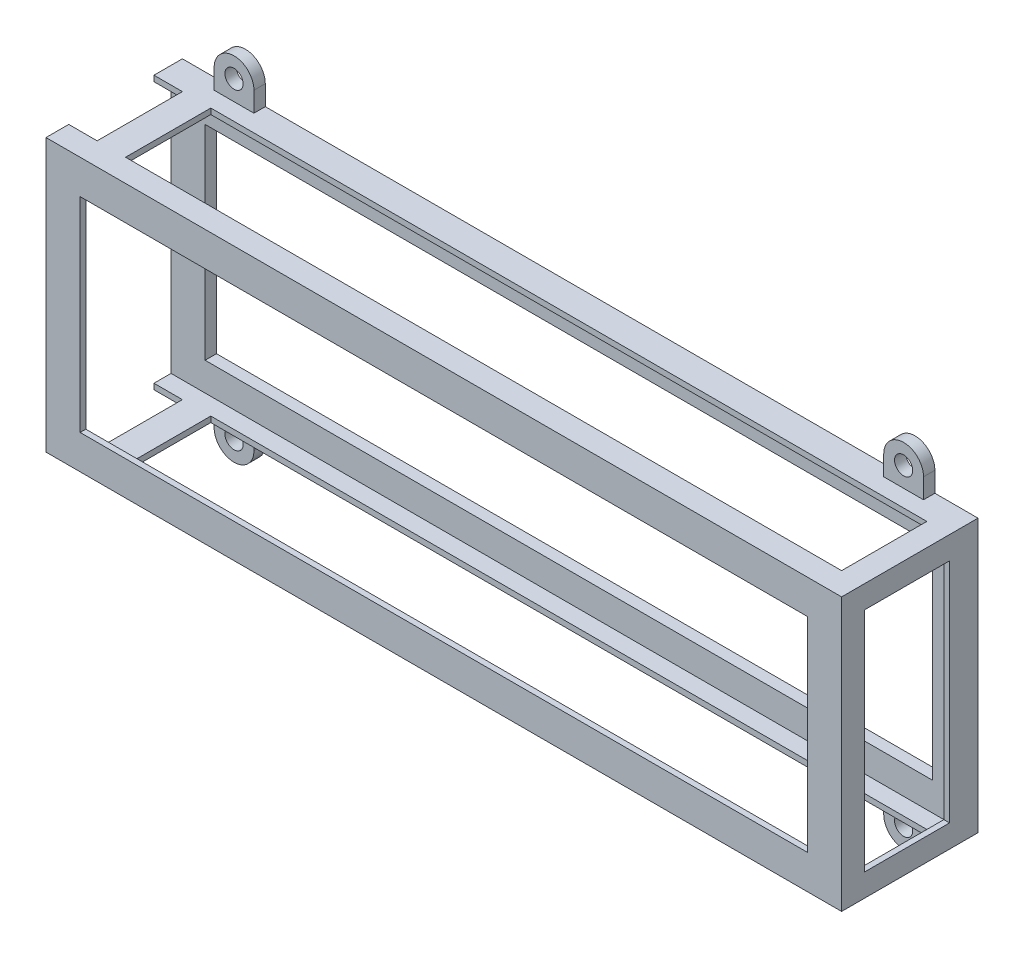
from build123d import *

# Parameters (mm, degrees)
SKETCH1_R           = 1.6
SKETCH1_R_2         = 2.1
BOSS_EXTRUDE3_DEPTH = 2
BOSS_EXTRUDE4_DEPTH = 2
SKETCH4_W           = 66
SKETCH4_H           = 16.340111315
SKETCH4_H_2         = 24.741581589
CUT_EXTRUDE3_DEPTH  = 14.5
FILLET1_R           = 4
SKETCH5_W           = 26
SKETCH5_H           = 27
SKETCH5_R           = 6
BOSS_EXTRUDE5_DEPTH = 2
SKETCH6_W           = 5
SKETCH6_H           = 27
CUT_EXTRUDE4_DEPTH  = 14.5
SKETCH7_R           = 1.6
SKETCH7_W           = 110.82382425
SKETCH7_H           = 47.94215156
BOSS_EXTRUDE6_DEPTH = 2
SKETCH8_W           = 110.82382425
SKETCH8_H           = 47.94215156
CUT_EXTRUDE5_DEPTH  = 10
BOSS_EXTRUDE7_DEPTH = 2
BOSS_EXTRUDE8_DEPTH = 21
SKETCH11_W          = 140
SKETCH11_H          = 47.94215156
BOSS_EXTRUDE9_DEPTH = 1
CUT_EXTRUDE7_DEPTH  = 13
CUT_EXTRUDE8_DEPTH  = 13
CUT_EXTRUDE9_DEPTH  = 66
CUT_EXTRUDE11_DEPTH = 66
CUT_EXTRUDE12_DEPTH = 66


with BuildPart() as part:
    # Sketch1 → Boss-Extrude3 (new body)
    with BuildSketch(Plane.XY):
        with BuildLine():
            Line((0, 3.5), (37.911912125, 3.5))
            Line((37.911912125, 3.5), (37.911912125, 13.97107578))
            Line((37.911912125, 13.97107578), (37.911912125, 40.97107578))
            Line((37.911912125, 40.97107578), (37.911912125, 51.44215156))
            Line((37.911912125, 51.44215156), (0, 51.44215156))
            ThreePointArc((0, 51.44215156), (-3.5, 54.94215156), (0, 58.44215156))
            Line((0, 58.44215156), (45.911912125, 58.44215156))
            Line((45.911912125, 58.44215156), (45.911912125, 51.44215156))
            Line((45.911912125, 51.44215156), (45.911912125, 48.97107578))
            Line((45.911912125, 48.97107578), (50.911912125, 48.97107578))
            Line((50.911912125, 48.97107578), (66.911912125, 48.97107578))
            Line((66.911912125, 48.97107578), (71.911912125, 48.97107578))
            Line((71.911912125, 48.97107578), (71.911912125, 51.44215156))
            Line((71.911912125, 51.44215156), (71.911912125, 58.44215156))
            Line((71.911912125, 58.44215156), (117.82382425, 58.44215156))
            ThreePointArc((117.82382425, 58.44215156), (121.32382425, 54.94215156), (117.82382425, 51.44215156))
            Line((117.82382425, 51.44215156), (79.911912125, 51.44215156))
            Line((79.911912125, 51.44215156), (79.911912125, 40.97107578))
            Line((79.911912125, 40.97107578), (79.911912125, 13.97107578))
            Line((79.911912125, 13.97107578), (79.911912125, 3.5))
            Line((79.911912125, 3.5), (117.82382425, 3.5))
            ThreePointArc((117.82382425, 3.5), (121.32382425, 0), (117.82382425, -3.5))
            Line((117.82382425, -3.5), (71.911912125, -3.5))
            Line((71.911912125, -3.5), (71.911912125, 3.5))
            Line((71.911912125, 3.5), (71.911912125, 5.97107578))
            Line((71.911912125, 5.97107578), (66.911912125, 5.97107578))
            Line((66.911912125, 5.97107578), (50.911912125, 5.97107578))
            Line((50.911912125, 5.97107578), (45.911912125, 5.97107578))
            Line((45.911912125, 5.97107578), (45.911912125, 3.5))
            Line((45.911912125, 3.5), (45.911912125, -3.5))
            Line((45.911912125, -3.5), (0, -3.5))
            ThreePointArc((0, -3.5), (-3.5, 0), (0, 3.5))
        make_face()
        with Locations((0, 54.94215156)):
            Circle(SKETCH1_R, mode=Mode.SUBTRACT)
        with Locations((117.82382425, 54.94215156)):
            Circle(SKETCH1_R, mode=Mode.SUBTRACT)
        with Locations((117.82382425, 0)):
            Circle(SKETCH1_R, mode=Mode.SUBTRACT)
        Circle(SKETCH1_R, mode=Mode.SUBTRACT)
        with Locations((66.911912125, 44.97107578)):
            Circle(SKETCH1_R_2, mode=Mode.SUBTRACT)
        with Locations((66.911912125, 9.97107578)):
            Circle(SKETCH1_R_2, mode=Mode.SUBTRACT)
        with Locations((50.911912125, 9.97107578)):
            Circle(SKETCH1_R_2, mode=Mode.SUBTRACT)
        with Locations((50.911912125, 44.97107578)):
            Circle(SKETCH1_R_2, mode=Mode.SUBTRACT)
        Polygon((66.911912125, 40.97107578), (50.911912125, 40.97107578), (45.911912125, 40.97107578), (45.911912125, 27.47107578), (45.911912125, 13.97107578), (50.911912125, 13.97107578), (66.911912125, 13.97107578), (71.911912125, 13.97107578), (71.911912125, 27.47107578), (71.911912125, 40.97107578), align=None, mode=Mode.SUBTRACT)
    extrude(amount=BOSS_EXTRUDE3_DEPTH)

    # Sketch3 → Boss-Extrude4 (add)
    with BuildSketch(Plane.XY.offset(2)):
        Polygon((71.911912125, 13.97107578), (99.911912125, 13.97107578), (99.911912125, 3.5), (91.911912125, 3.5), (91.911912125, 5.97107578), (71.911912125, 5.97107578), align=None)
        Polygon((91.911912125, 51.44215156), (99.911912125, 51.44215156), (99.911912125, 40.97107578), (71.911912125, 40.97107578), (71.911912125, 48.97107578), (91.911912125, 48.97107578), align=None)
        Polygon((45.911912125, 40.97107578), (17.911912125, 40.97107578), (17.911912125, 51.44215156), (25.911912125, 51.44215156), (25.911912125, 48.97107578), (45.911912125, 48.97107578), align=None)
        Polygon((25.911912125, 3.5), (17.911912125, 3.5), (17.911912125, 13.97107578), (45.911912125, 13.97107578), (45.911912125, 5.97107578), (25.911912125, 5.97107578), align=None)
    extrude(amount=-BOSS_EXTRUDE4_DEPTH)

    # Sketch4 → Cut-Extrude3 (cut)
    with BuildSketch(Plane.XY.offset(2)):
        with Locations((58.911912125, 57.141131438)):
            Rectangle(SKETCH4_W, SKETCH4_H)
        with Locations((58.911912125, -6.399715014)):
            Rectangle(SKETCH4_W, SKETCH4_H_2)
    extrude(amount=-CUT_EXTRUDE3_DEPTH, mode=Mode.SUBTRACT)

    # Fillet1
    fillet1_edges = [part.edges().sort_by_distance(p)[0] for p in [
        (99.911912125, 13.97107578, 1),
        (99.911912125, 3.5, 1),
        (91.911912125, 5.97107578, 1),
        (91.911912125, 48.97107578, 1),
        (99.911912125, 51.44215156, 1),
        (99.911912125, 40.97107578, 1),
        (17.911912125, 40.97107578, 1),
        (17.911912125, 51.44215156, 1),
        (25.911912125, 48.97107578, 1),
        (25.911912125, 5.97107578, 1),
        (17.911912125, 3.5, 1),
        (17.911912125, 13.97107578, 1),
        (91.911912125, 58.44215156, 1),
        (25.911912125, 58.44215156, 1),
        (91.911912125, -3.5, 1),
        (25.911912125, -3.5, 1),
    ]]
    fillet(fillet1_edges, radius=FILLET1_R)

    # Sketch5 → Boss-Extrude5 (add)
    with BuildSketch(Plane.XY.offset(2)):
        with Locations((58.911912125, 27.47107578)):
            Rectangle(SKETCH5_W, SKETCH5_H)
        with Locations((58.911912125, 27.47107578)):
            Circle(SKETCH5_R, mode=Mode.SUBTRACT)
    extrude(amount=-BOSS_EXTRUDE5_DEPTH)

    # Sketch6 → Cut-Extrude4 (cut)
    with BuildSketch(Plane.XY.offset(2)):
        with Locations((40.411912125, 27.47107578)):
            Rectangle(SKETCH6_W, SKETCH6_H)
        with Locations((77.411912125, 27.47107578)):
            Rectangle(SKETCH6_W, SKETCH6_H)
    extrude(amount=-CUT_EXTRUDE4_DEPTH, mode=Mode.SUBTRACT)

    # Sketch7 → Boss-Extrude6 (add)
    with BuildSketch(Plane.XY.offset(2)):
        with BuildLine():
            Line((-3.5, 54.94215156), (-3.5, 0))
            ThreePointArc((-3.5, 0), (-2.474873734, -2.474873734), (0, -3.5))
            Line((0, -3.5), (117.82382425, -3.5))
            ThreePointArc((117.82382425, -3.5), (120.298697984, -2.474873734), (121.32382425, 0))
            Line((121.32382425, 0), (121.32382425, 54.94215156))
            ThreePointArc((121.32382425, 54.94215156), (120.298697984, 57.417025294), (117.82382425, 58.44215156))
            Line((117.82382425, 58.44215156), (0, 58.44215156))
            ThreePointArc((0, 58.44215156), (-2.474873734, 57.417025294), (-3.5, 54.94215156))
        make_face()
        Circle(SKETCH7_R, mode=Mode.SUBTRACT)
        with Locations((117.82382425, 0)):
            Circle(SKETCH7_R, mode=Mode.SUBTRACT)
        with Locations((117.82382425, 54.94215156)):
            Circle(SKETCH7_R, mode=Mode.SUBTRACT)
        with Locations((0, 54.94215156)):
            Circle(SKETCH7_R, mode=Mode.SUBTRACT)
        with Locations((58.911912125, 27.47107578)):
            Rectangle(SKETCH7_W, SKETCH7_H, mode=Mode.SUBTRACT)
    extrude(amount=-BOSS_EXTRUDE6_DEPTH)

    # Sketch8 → Cut-Extrude5 (cut)
    with BuildSketch(Plane.XY.offset(2)):
        with Locations((58.911912125, 27.47107578)):
            Rectangle(SKETCH8_W, SKETCH8_H)
    extrude(amount=-CUT_EXTRUDE5_DEPTH, mode=Mode.SUBTRACT)

    # Sketch9 → Boss-Extrude7 (add)
    with BuildSketch(Plane.XY.offset(2)):
        Polygon((58.911912125, 51.44215156), (128.911912125, 51.44215156), (128.911912125, 3.5), (-11.088087875, 3.5), (-11.088087875, 51.44215156), align=None)
    extrude(amount=-BOSS_EXTRUDE7_DEPTH)

    # Sketch10 → Boss-Extrude8 (add)
    with BuildSketch(Plane.XY.offset(2)):
        Polygon((-11.088087875, 51.44215156), (128.911912125, 51.44215156), (128.911912125, 3.5), (-11.088087875, 3.5), (-11.088087875, 4.5), (127.911912125, 4.5), (127.911912125, 27.47107578), (127.911912125, 50.44215156), (-11.088087875, 50.44215156), align=None)
    extrude(amount=BOSS_EXTRUDE8_DEPTH)

    # Sketch11 → Boss-Extrude9 (add)
    with BuildSketch(Plane.XY.offset(23)):
        with Locations((58.911912125, 27.47107578)):
            Rectangle(SKETCH11_W, SKETCH11_H)
    extrude(amount=BOSS_EXTRUDE9_DEPTH)

    # Sketch12 → Cut-Extrude7 (cut)
    with BuildSketch(Plane.XY.offset(2)):
        with BuildLine():
            Line((3.5, 0), (3.5, 3.5))
            Line((3.5, 3.5), (114.32382425, 3.5))
            Line((114.32382425, 3.5), (114.32382425, 0))
            ThreePointArc((114.32382425, 0), (115.348950516, -2.474873734), (117.82382425, -3.5))
            Line((117.82382425, -3.5), (0, -3.5))
            ThreePointArc((0, -3.5), (2.474873734, -2.474873734), (3.5, 0))
        make_face()
        with BuildLine():
            Line((3.5, 54.94215156), (3.5, 51.44215156))
            Line((3.5, 51.44215156), (114.32382425, 51.44215156))
            Line((114.32382425, 51.44215156), (114.32382425, 54.94215156))
            ThreePointArc((114.32382425, 54.94215156), (115.348950516, 57.417025294), (117.82382425, 58.44215156))
            Line((117.82382425, 58.44215156), (0, 58.44215156))
            ThreePointArc((0, 58.44215156), (2.474873734, 57.417025294), (3.5, 54.94215156))
        make_face()
    extrude(amount=-CUT_EXTRUDE7_DEPTH, mode=Mode.SUBTRACT)

    # Sketch13 → Cut-Extrude8 (cut)
    with BuildSketch(Plane(origin=(128.911912125, 0, 0), x_dir=(0, 0, -1), z_dir=(1, 0, 0))):
        Polygon((-20, 27.47107578), (-20, 47.44215156), (-5, 47.44215156), (-5, 7.5), (-20, 7.5), align=None)
    extrude(amount=-CUT_EXTRUDE8_DEPTH, mode=Mode.SUBTRACT)

    # Sketch14 → Cut-Extrude9 (cut)
    with BuildSketch(Plane(origin=(0, 0, 0), x_dir=(-1, 0, 0), z_dir=(0, 0, -1))):
        Polygon((-58.911912125, 9.5), (-122.911912125, 9.5), (-122.911912125, 45.44215156), (5.088087875, 45.44215156), (5.088087875, 9.5), align=None)
    extrude(amount=-CUT_EXTRUDE9_DEPTH, mode=Mode.SUBTRACT)

    # Sketch15 → Cut-Extrude11 (cut)
    with BuildSketch(Plane(origin=(0, 51.44215156, 0), x_dir=(1, 0, 0), z_dir=(0, 1, 0))):
        Polygon((-1.088087875, -5), (-1.088087875, -12), (-1.088087875, -20), (124.911912125, -20), (124.911912125, -5), (58.911912125, -5), align=None)
    extrude(amount=-CUT_EXTRUDE11_DEPTH, mode=Mode.SUBTRACT)

    # Sketch16 → Cut-Extrude12 (cut)
    with BuildSketch(Plane(origin=(0, 51.44215156, 0), x_dir=(1, 0, 0), z_dir=(0, 1, 0))):
        Polygon((-6.088087875, -12), (-6.088087875, -5), (-11.088087875, -5), (-11.088087875, -20), (-6.088087875, -20), align=None)
    extrude(amount=-CUT_EXTRUDE12_DEPTH, mode=Mode.SUBTRACT)


solid = part.part
